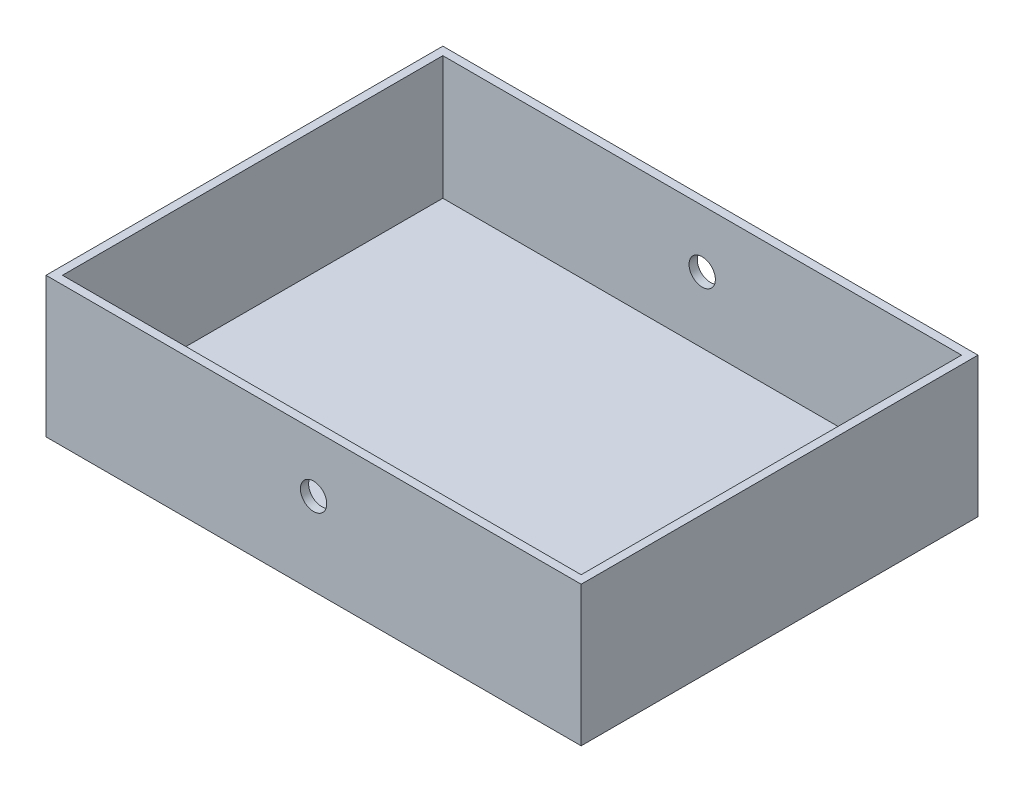
from build123d import *

# Parameters (mm, degrees)
SKETCH1_W           = 650
SKETCH1_H           = 170
BOSS_EXTRUDE1_DEPTH = 482
SKETCH2_R           = 16
CUT_EXTRUDE1_DEPTH  = 483
SKETCH3_W           = 630
SKETCH3_H           = 462
CUT_EXTRUDE2_DEPTH  = 150


with BuildPart() as part:
    # Sketch1 → Boss-Extrude1 (new body)
    with BuildSketch(Plane.XY):
        Rectangle(SKETCH1_W, SKETCH1_H)
    extrude(amount=BOSS_EXTRUDE1_DEPTH)

    # Sketch2 → Cut-Extrude1 (cut, through all)
    with BuildSketch(Plane(origin=(0, 0, 0), x_dir=(-1, 0, 0), z_dir=(0, 0, -1))):
        with Locations((0, 15)):
            Circle(SKETCH2_R)
    extrude(amount=-CUT_EXTRUDE1_DEPTH, mode=Mode.SUBTRACT)

    # Sketch3 → Cut-Extrude2 (cut)
    with BuildSketch(Plane(origin=(0, 85, 0), x_dir=(1, 0, 0), z_dir=(0, 1, 0))):
        with Locations((0, -241)):
            Rectangle(SKETCH3_W, SKETCH3_H)
    extrude(amount=-CUT_EXTRUDE2_DEPTH, mode=Mode.SUBTRACT)


solid = part.part
